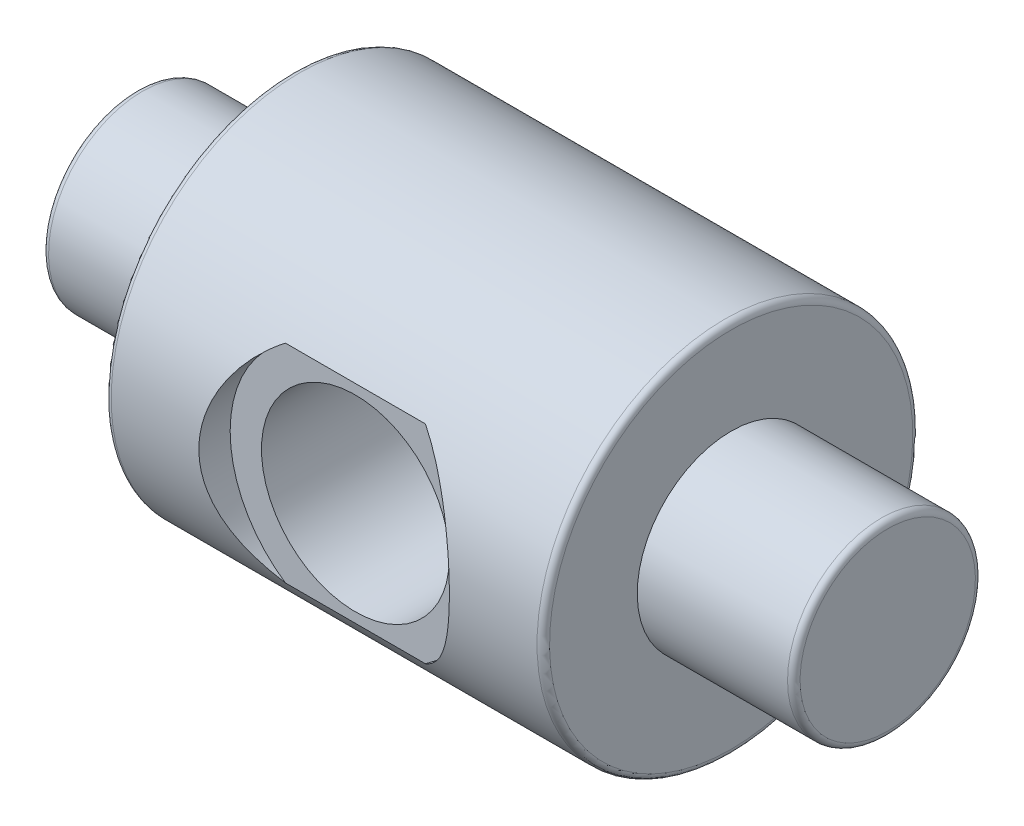
from build123d import *

# Parameters (mm, degrees)
FILLET1_R          = 0.1
SKETCH2_R          = 2
CUT_EXTRUDE1_DEPTH = 0.5
CUT_EXTRUDE2_REACH = 7.5
SKETCH3_R          = 1.5


with BuildPart() as part:
    # Sketch1 → Revolve1 (revolve)
    with BuildSketch(Plane.XY):
        Polygon((0, 0), (-4.054195804, 0), (-4.054195804, -1.5), (-1.554195804, -1.5), (-1.554195804, -3), (5.445804196, -3), (5.445804196, -1.5), (7.945804196, -1.5), (7.945804196, 0), align=None)
    revolve(axis=Axis((7.945804196, 0, 0), (-1, 0, 0)))

    # Fillet1
    fillet1_edges = [part.edges().sort_by_distance(p)[0] for p in [
        (7.945804196, 1.5, 0),
        (5.445804196, 3, 0),
        (-1.554195804, 3, 0),
        (-4.054195804, 1.5, 0),
    ]]
    fillet(fillet1_edges, radius=FILLET1_R)

    # Sketch2 → Cut-Extrude1 (cut)
    with BuildSketch(Plane.XY.offset(3)):
        with Locations((1.945804196, 0)):
            Circle(SKETCH2_R)
    extrude(amount=-CUT_EXTRUDE1_DEPTH, mode=Mode.SUBTRACT)

    # Sketch3 → Cut-Extrude2 (cut, up to next)
    with BuildSketch(Plane.XY.offset(2.5), mode=Mode.PRIVATE) as cut_extrude2_sk1:
        with Locations((1.945804196, 0)):
            Circle(SKETCH3_R)
    cut_extrude2_tool1 = extrude(cut_extrude2_sk1.sketch, amount=-CUT_EXTRUDE2_REACH, mode=Mode.PRIVATE) & part.part
    add(cut_extrude2_tool1.solids().sort_by_distance((1.945804, 0, 2.5))[0], mode=Mode.SUBTRACT)


solid = part.part
